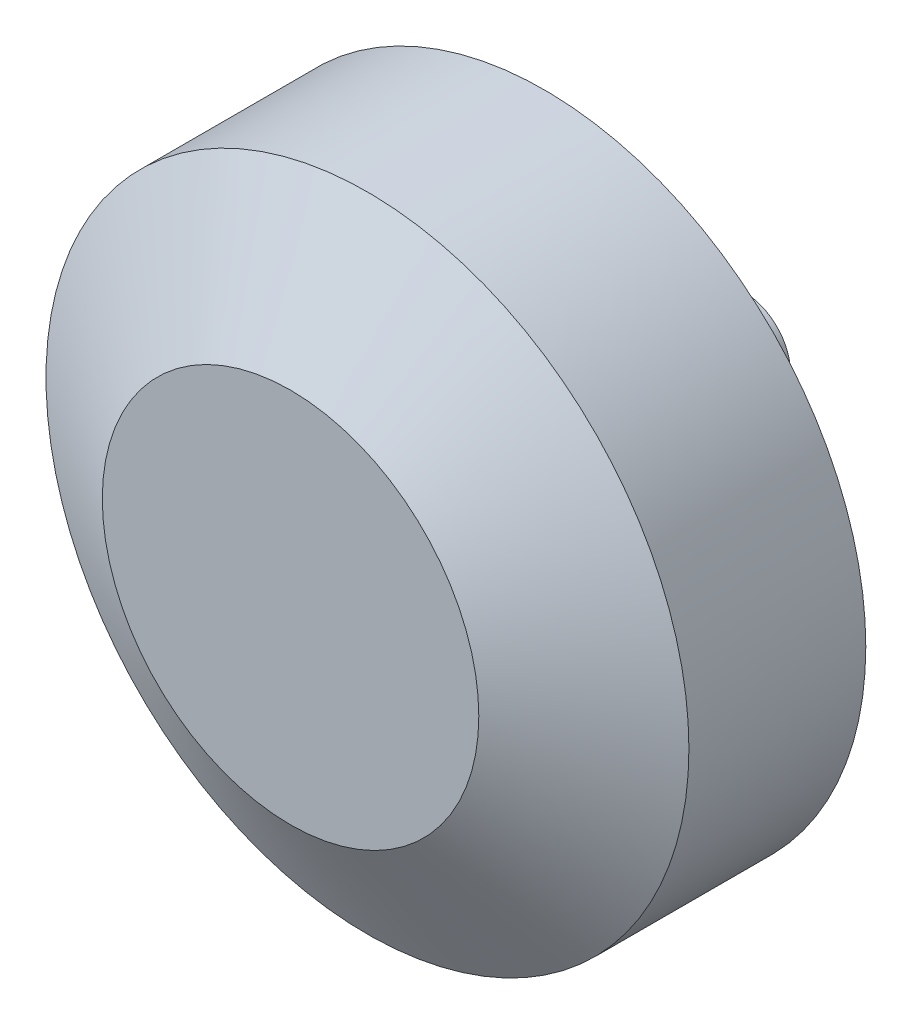
from build123d import *

# Parameters (mm, degrees)
SCHIZZO2_R                   = 20.9
ESTRUSIONE_ESTRUSIONE1_DEPTH = 10.75
SCHIZZO3_R                   = 3
ESTRUSIONE_ESTRUSIONE2_DEPTH = 8
SMUSSO1_SIZE                 = 5
SMUSSO1_SIZE2                = 8.660254038


with BuildPart() as part:
    # Schizzo2 → Estrusione-Estrusione1 (new, symmetric)
    with BuildSketch(Plane.XY):
        Circle(SCHIZZO2_R)
    extrude(amount=ESTRUSIONE_ESTRUSIONE1_DEPTH, both=True)

    # Schizzo3 → Estrusione-Estrusione2 (add)
    with BuildSketch(Plane(origin=(0, 0, -10.75), x_dir=(-1, 0, 0), z_dir=(0, 0, -1))):
        Circle(SCHIZZO3_R)
    extrude(amount=ESTRUSIONE_ESTRUSIONE2_DEPTH)

    # Smusso1
    smusso1_edges = [part.edges().sort_by_distance(p)[0] for p in [
        (-20.9, 0, 10.75),
        (-20.9, 0, -10.75),
    ]]
    smusso1_side = [part.faces().sort_by_distance(p)[0] for p in [
        (-20.9, 0, 0),
    ]]
    chamfer(smusso1_edges, length=SMUSSO1_SIZE, length2=SMUSSO1_SIZE2, reference=smusso1_side[0])


solid = part.part
